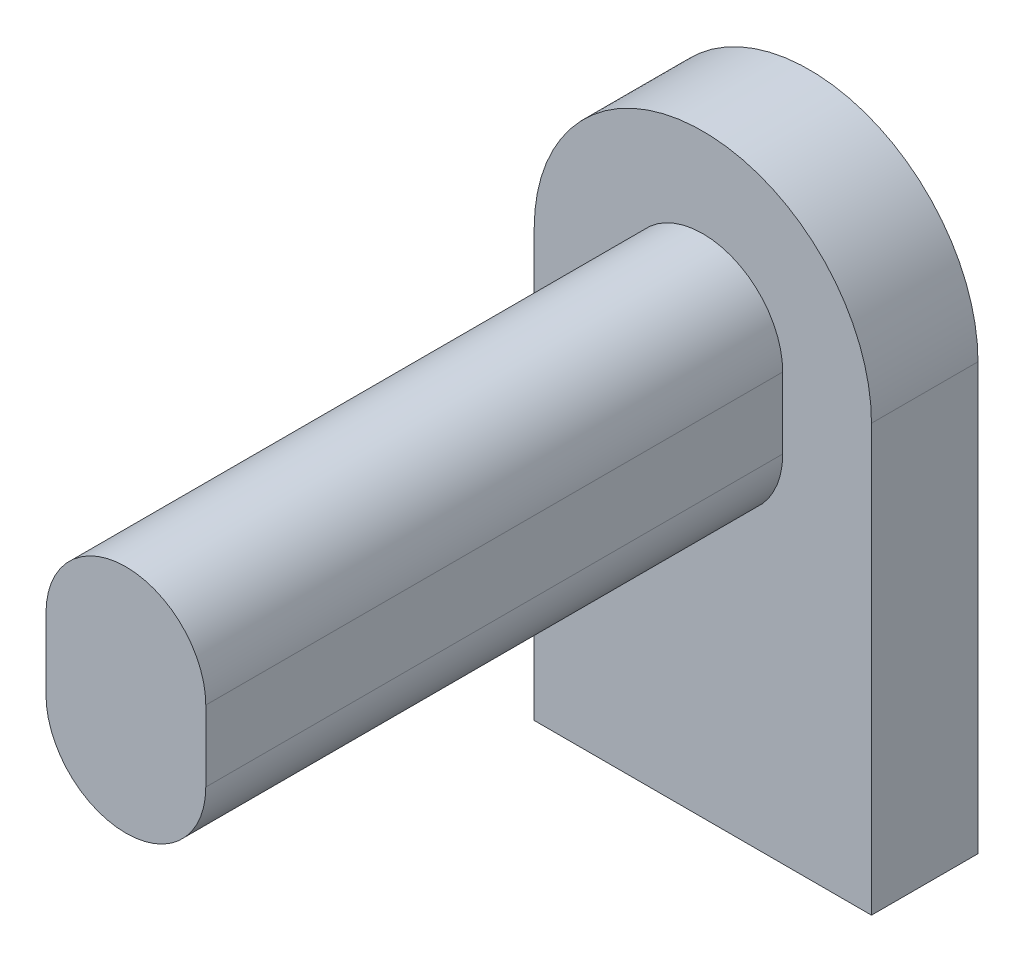
from build123d import *

# Parameters (mm, degrees)
BOSS_EXTRUDE1_DEPTH = 6.5
BOSS_EXTRUDE2_DEPTH = 1.2


with BuildPart() as part:
    # Sketch1 → Boss-Extrude1 (new body)
    with BuildSketch(Plane.XY):
        with BuildLine():
            Line((-54.735153148, 20.85842627), (-54.735153148, 20.05842627))
            ThreePointArc((-54.735153148, 20.05842627), (-53.835153148, 19.15842627), (-52.935153148, 20.05842627))
            Line((-52.935153148, 20.05842627), (-52.935153148, 20.85842627))
            ThreePointArc((-52.935153148, 20.85842627), (-53.835153148, 21.75842627), (-54.735153148, 20.85842627))
        make_face()
    extrude(amount=BOSS_EXTRUDE1_DEPTH)

    # Sketch3 → Boss-Extrude2 (add)
    with BuildSketch(Plane(origin=(0, 0, 0), x_dir=(-1, 0, 0), z_dir=(0, 0, -1))):
        with BuildLine():
            Line((51.935153148, 20.85842627), (51.935153148, 16.05842627))
            Line((51.935153148, 16.05842627), (55.735153148, 16.05842627))
            Line((55.735153148, 16.05842627), (55.735153148, 20.85842627))
            ThreePointArc((55.735153148, 20.85842627), (53.835153148, 22.75842627), (51.935153148, 20.85842627))
        make_face()
    extrude(amount=BOSS_EXTRUDE2_DEPTH)


solid = part.part
